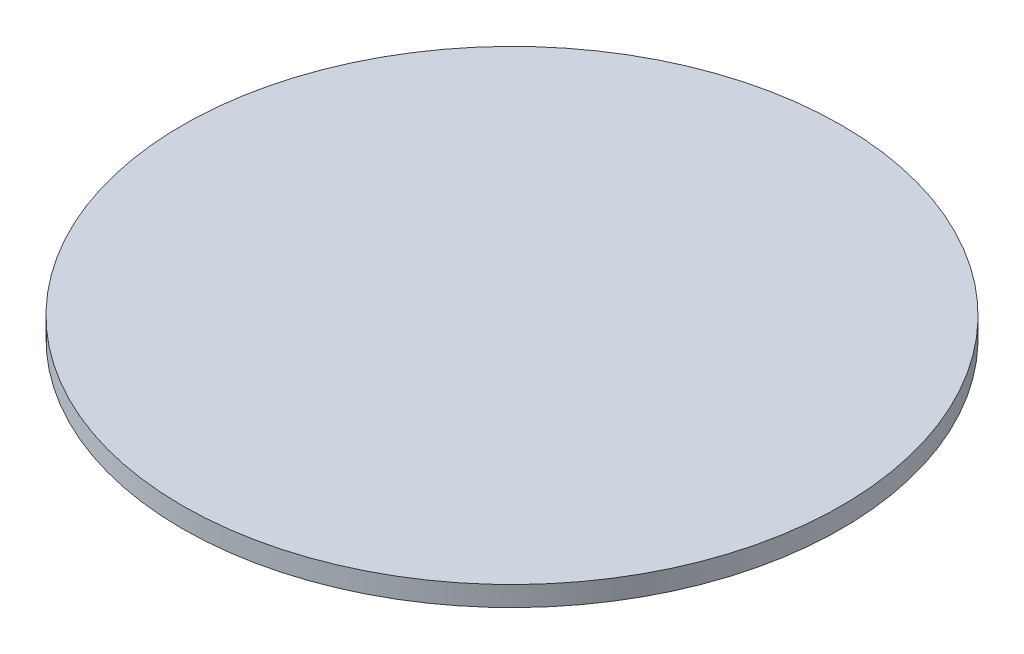
from build123d import *


with BuildPart() as part:
    # Эскиз1 → Повернуть1 (revolve)
    with BuildSketch(Plane.XY):
        Polygon((0, 0), (0, 2), (16.5, 2), (16.5, 1), (13.5, 1), (13.5, 0), align=None)
    revolve(axis=Axis((0, 0, 0), (0, 1, 0)))


solid = part.part
